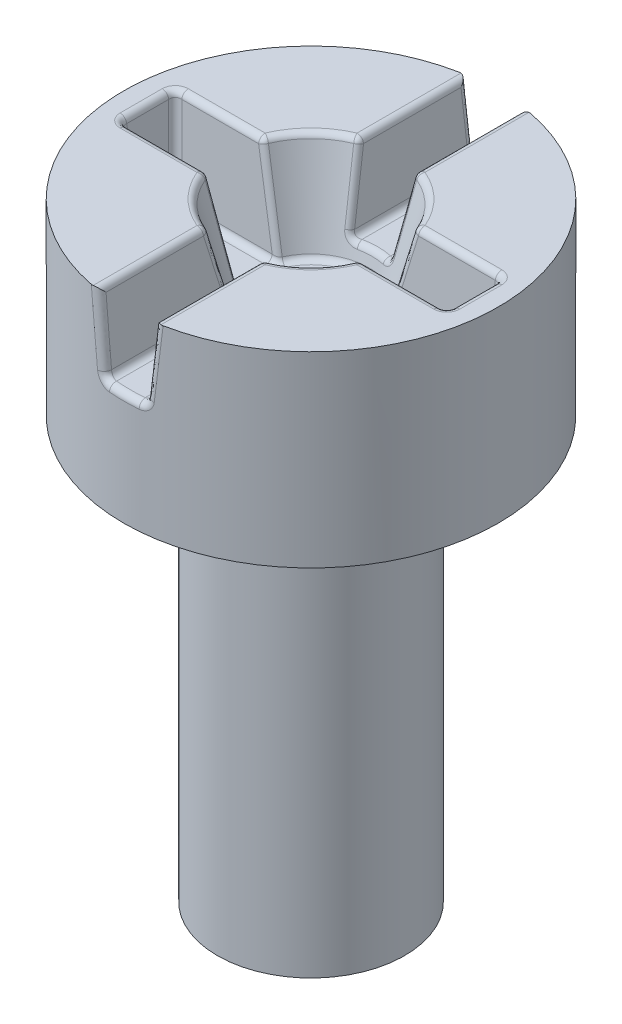
from build123d import *

# Parameters (mm, degrees)
SKETCH1_R           = 1
BOSS_EXTRUDE1_DEPTH = 4.5
SKETCH2_R           = 2
BOSS_EXTRUDE2_DEPTH = 2
SKETCH3_W           = 3.5
SKETCH3_H           = 0.6
CUT_EXTRUDE1_DEPTH  = 1
CUT_EXTRUDE1_TAPER  = 5
SKETCH4_W           = 0.6
SKETCH4_H           = 5
CUT_EXTRUDE2_DEPTH  = 0.8
CUT_EXTRUDE2_TAPER  = 6
SKETCH5_R           = 0.875
CUT_EXTRUDE3_DEPTH  = 1
CUT_EXTRUDE3_TAPER  = 15
FILLET1_R           = 0.07


with BuildPart() as part:
    # Sketch1 → Boss-Extrude1 (new body)
    with BuildSketch(Plane(origin=(0, 0, 0), x_dir=(1, 0, 0), z_dir=(0, 1, 0))):
        Circle(SKETCH1_R)
    extrude(amount=-BOSS_EXTRUDE1_DEPTH)

    # Sketch2 → Boss-Extrude2 (add)
    with BuildSketch(Plane(origin=(0, 0, 0), x_dir=(1, 0, 0), z_dir=(0, 1, 0))):
        Circle(SKETCH2_R)
    extrude(amount=BOSS_EXTRUDE2_DEPTH)

    # Sketch3 → Cut-Extrude1 (cut)
    with BuildSketch(Plane(origin=(0, 2, 0), x_dir=(1, 0, 0), z_dir=(0, 1, 0))):
        Rectangle(SKETCH3_W, SKETCH3_H)
    extrude(amount=-CUT_EXTRUDE1_DEPTH, taper=CUT_EXTRUDE1_TAPER, mode=Mode.SUBTRACT)

    # Sketch4 → Cut-Extrude2 (cut)
    with BuildSketch(Plane(origin=(0, 2, 0), x_dir=(1, 0, 0), z_dir=(0, 1, 0))):
        Rectangle(SKETCH4_W, SKETCH4_H)
    extrude(amount=-CUT_EXTRUDE2_DEPTH, taper=CUT_EXTRUDE2_TAPER, mode=Mode.SUBTRACT)

    # Sketch5 → Cut-Extrude3 (cut)
    with BuildSketch(Plane(origin=(0, 2, 0), x_dir=(1, 0, 0), z_dir=(0, 1, 0))):
        Circle(SKETCH5_R)
    extrude(amount=-CUT_EXTRUDE3_DEPTH, taper=CUT_EXTRUDE3_TAPER, mode=Mode.SUBTRACT)

    # Fillet1
    fillet1_edges = [part.edges().sort_by_distance(p)[0] for p in [
        (1.662511336, 1, 0),
        (1.706255668, 1.5, -0.256255668),
        (-1.115574862, 1, 0.212511336),
        (1.706255668, 1.5, 0.256255668),
        (-1.706255668, 1.5, 0.256255668),
        (1.115574862, 1, -0.212511336),
        (-1.706255668, 1.5, -0.256255668),
        (1.75, 2, 0),
        (1.285982056, 2, -0.3),
        (-1.75, 2, 0),
        (-1.285982056, 2, 0.3),
        (0.25795895, 1.600006129, -1.983294527),
        (0.25795895, 1.600006129, 1.983294527),
        (0.215916612, 1.2, 1.306335691),
        (-0.25795895, 1.600006129, 1.983294527),
        (-0.25795895, 1.600006129, -1.983294527),
        (-0.215916612, 1.2, -1.306335691),
        (0, 1.2, 2),
        (0, 1.2, -2),
        (-0.3, 2, -1.399668052),
        (0.3, 2, 1.399668052),
        (-0.215916612, 1.2, 1.306335691),
        (0, 1.2, 0.660640646),
        (-0.3, 2, 1.399668052),
        (0.215916612, 1.2, -1.306335691),
        (0.3, 2, -1.399668052),
        (-1.115574862, 1, -0.212511336),
        (1.115574862, 1, 0.212511336),
        (-1.285982056, 2, -0.3),
        (1.285982056, 2, 0.3),
        (0, 1, 0.607050808),
        (0, 1, -0.607050808),
        (-0.618718434, 2, -0.618718434),
        (0.618718434, 2, -0.618718434),
        (0.618718434, 2, 0.618718434),
        (-0.618718434, 2, 0.618718434),
        (-0.695306559, 1.499998665, 0.256255551),
        (0.695306559, 1.499998665, 0.256255551),
        (0.257957606, 1.599993339, 0.723189588),
        (-0.257957606, 1.599993339, 0.723189588),
        (0.695306559, 1.499998665, -0.256255551),
        (-0.695306557, 1.499998666, -0.256255551),
        (-0.257957606, 1.59999334, -0.723189586),
        (0.257957606, 1.599993339, -0.723189588),
        (0, 1.2, -0.660640646),
    ]]
    fillet(fillet1_edges, radius=FILLET1_R)


solid = part.part
